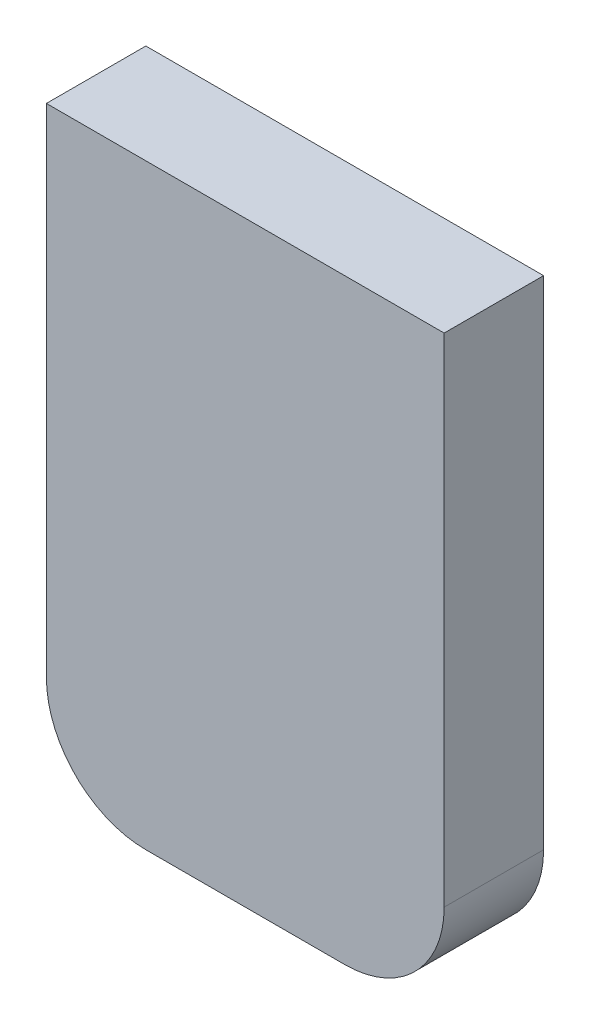
from build123d import *

# Parameters (mm, degrees)
SALIENTE_EXTRUIR1_DEPTH      = 50
CROQUIS2_W                   = 40
CROQUIS2_H                   = 50
SALIENTE_EXTRUIR2_DEPTH      = 60
SALIENTE_EXTRUIR2_DEPTH_BACK = 31
REDONDEO1_R                  = 10
REDONDEO2_R                  = 10
CORTAR_EXTRUIR1_DEPTH        = 74
VACIADO1_T                   = -3
CROQUIS4_W                   = 26.4
CROQUIS4_H                   = 56
CROQUIS4_W_2                 = 20.4
CROQUIS4_H_2                 = 50
SALIENTE_EXTRUIR3_DEPTH      = 7


with BuildPart() as part:
    # Croquis1 → Saliente-Extruir1 (new body)
    with BuildSketch(Plane.XY):
        with BuildLine():
            Line((-80.606796451, 54.173553719), (-40.606796451, 54.173553719))
            ThreePointArc((-40.606796451, 54.173553719), (-33.53572864, 51.244621531), (-30.606796451, 44.173553719))
            Line((-30.606796451, 44.173553719), (-30.606796451, 4.173553719))
            ThreePointArc((-30.606796451, 4.173553719), (-33.53572864, -2.897514093), (-40.606796451, -5.826446281))
            Line((-40.606796451, -5.826446281), (-80.606796451, -5.826446281))
            ThreePointArc((-80.606796451, -5.826446281), (-87.677864263, -2.897514093), (-90.606796451, 4.173553719))
            Line((-90.606796451, 4.173553719), (-90.606796451, 44.173553719))
            ThreePointArc((-90.606796451, 44.173553719), (-87.677864263, 51.244621531), (-80.606796451, 54.173553719))
        make_face()
    extrude(amount=SALIENTE_EXTRUIR1_DEPTH)

    # Croquis2 → Saliente-Extruir2 (add, two sides)
    with BuildSketch(Plane.XZ.offset(5.826446281)) as saliente_extruir2_sk:
        with Locations((-50.606796451, 25)):
            Rectangle(CROQUIS2_W, CROQUIS2_H)
    extrude(amount=SALIENTE_EXTRUIR2_DEPTH)
    extrude(saliente_extruir2_sk.sketch, amount=-SALIENTE_EXTRUIR2_DEPTH_BACK)

    # Redondeo1
    redondeo1_edges = [part.edges().sort_by_distance(p)[0] for p in [
        (-30.606796451, -65.826446281, 25),
    ]]
    fillet(redondeo1_edges, radius=REDONDEO1_R)

    # Redondeo2
    redondeo2_edges = [part.edges().sort_by_distance(p)[0] for p in [
        (-70.606796451, -65.826446281, 25),
    ]]
    fillet(redondeo2_edges, radius=REDONDEO2_R)

    # Croquis3 → Cortar-Extruir1 (cut)
    with BuildSketch(Plane(origin=(-30.606796451, 0, 0), x_dir=(0, 0, -1), z_dir=(1, 0, 0))):
        Polygon((-40, -65.826446281), (-40, -5.826446281), (-50, -5.826446281), (-90.954417086, -5.826446281), (-90.954417086, 59.755258828), (17.577829589, 59.755258828), (17.577829589, -73.598263991), (-40, -73.598263991), align=None)
    extrude(amount=-CORTAR_EXTRUIR1_DEPTH, mode=Mode.SUBTRACT)

    # Vaciado1
    vaciado1_openings = [part.faces().sort_by_distance(p)[0] for p in [
        (-50.606796451, -43.183468885, 40),
    ]]
    offset(amount=VACIADO1_T, openings=vaciado1_openings, kind=Kind.INTERSECTION)

    # Croquis4 → Saliente-Extruir3 (add)
    with BuildSketch(Plane(origin=(0, 0, 47), x_dir=(-1, 0, 0), z_dir=(0, 0, -1))):
        with Locations((50.606796451, -36.026446281)):
            Rectangle(CROQUIS4_W, CROQUIS4_H)
        with Locations((50.606796451, -36.026446281)):
            Rectangle(CROQUIS4_W_2, CROQUIS4_H_2, mode=Mode.SUBTRACT)
    extrude(amount=SALIENTE_EXTRUIR3_DEPTH)


solid = part.part
